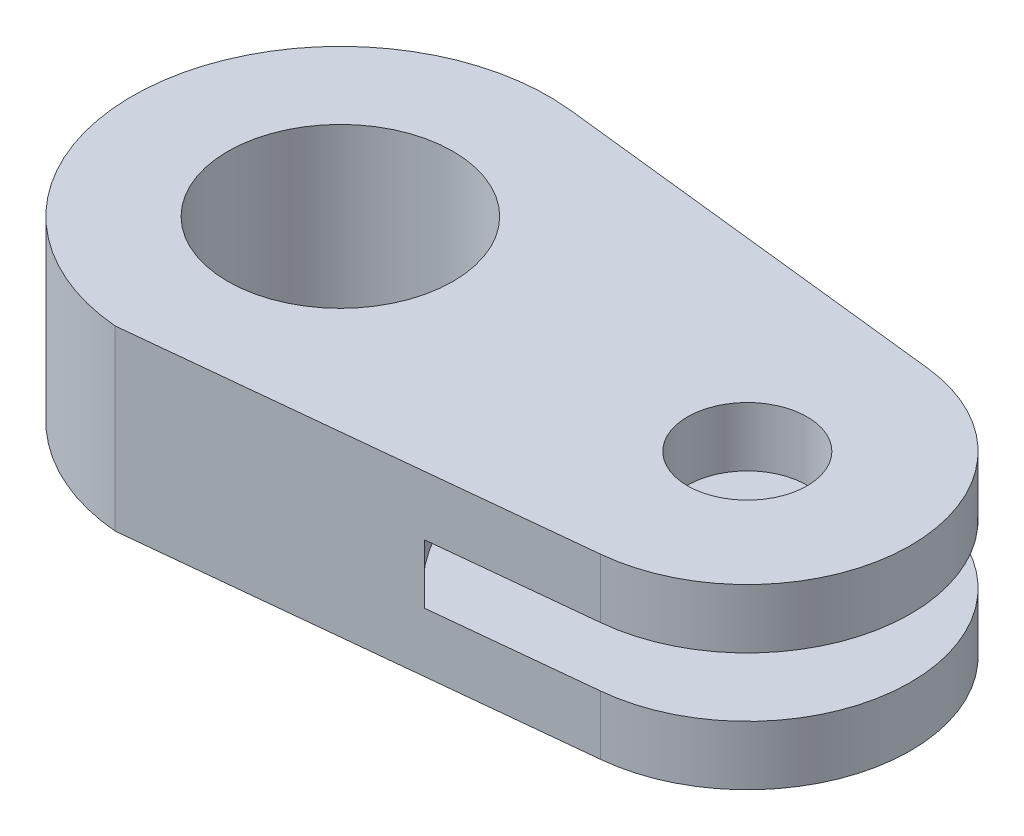
from build123d import *

# Parameters (mm, degrees)
SKETCH_1_R          = 30.428996358
SKETCH_1_R_2        = 16.155751461
EXTRUDE_2_DEPTH     = 24
SKETCH_2_R          = 62
CUT_EXTRUDE_1_DEPTH = 8


with BuildPart() as part:
    # Эскиз1 → Бобышка-Вытянуть2 (new body, symmetric)
    with BuildSketch(Plane(origin=(0, 0, 0), x_dir=(1, 0, 0), z_dir=(0, 1, 0))):
        with BuildLine():
            Line((6.227294987, 55.90193086), (114.792593034, 43.808106445))
            ThreePointArc((114.792593034, 43.808106445), (153.990225093, -0.347161193), (114.101954958, -43.879539083))
            Line((114.101954958, -43.879539083), (-4.795118465, -56.042947064))
            ThreePointArc((-4.795118465, -56.042947064), (-55.977019444, 5.511657733), (6.227294987, 55.90193086))
        make_face()
        Circle(SKETCH_1_R, mode=Mode.SUBTRACT)
        with Locations((109.912511122, 0)):
            Circle(SKETCH_1_R_2, mode=Mode.SUBTRACT)
    extrude(amount=EXTRUDE_2_DEPTH, both=True)

    # Эскиз2 → Вырез-Вытянуть1 (cut, symmetric)
    with BuildSketch(Plane(origin=(0, 0, 0), x_dir=(1, 0, 0), z_dir=(0, 1, 0))):
        with Locations((109.912511122, 0)):
            Circle(SKETCH_2_R)
    extrude(amount=CUT_EXTRUDE_1_DEPTH, both=True, mode=Mode.SUBTRACT)


solid = part.part
